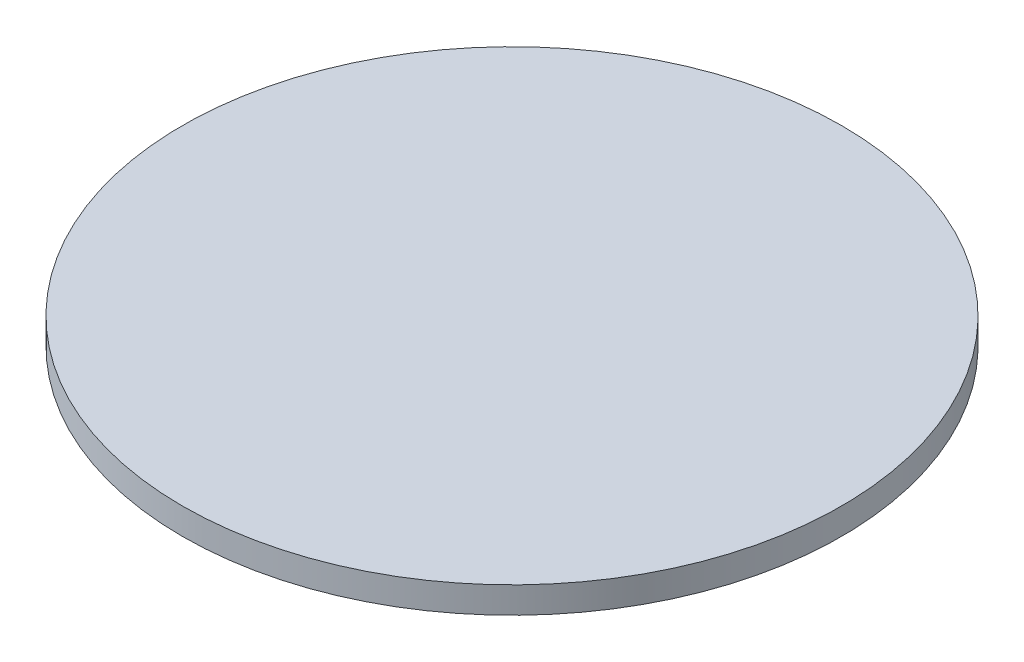
from build123d import *

# Parameters (mm, degrees)
SKETCH1_R           = 25
BOSS_EXTRUDE1_DEPTH = 2


with BuildPart() as part:
    # Sketch1 → Boss-Extrude1 (new body)
    with BuildSketch(Plane(origin=(0, 0, 0), x_dir=(1, 0, 0), z_dir=(0, 1, 0))):
        Circle(SKETCH1_R)
    extrude(amount=BOSS_EXTRUDE1_DEPTH)


solid = part.part
